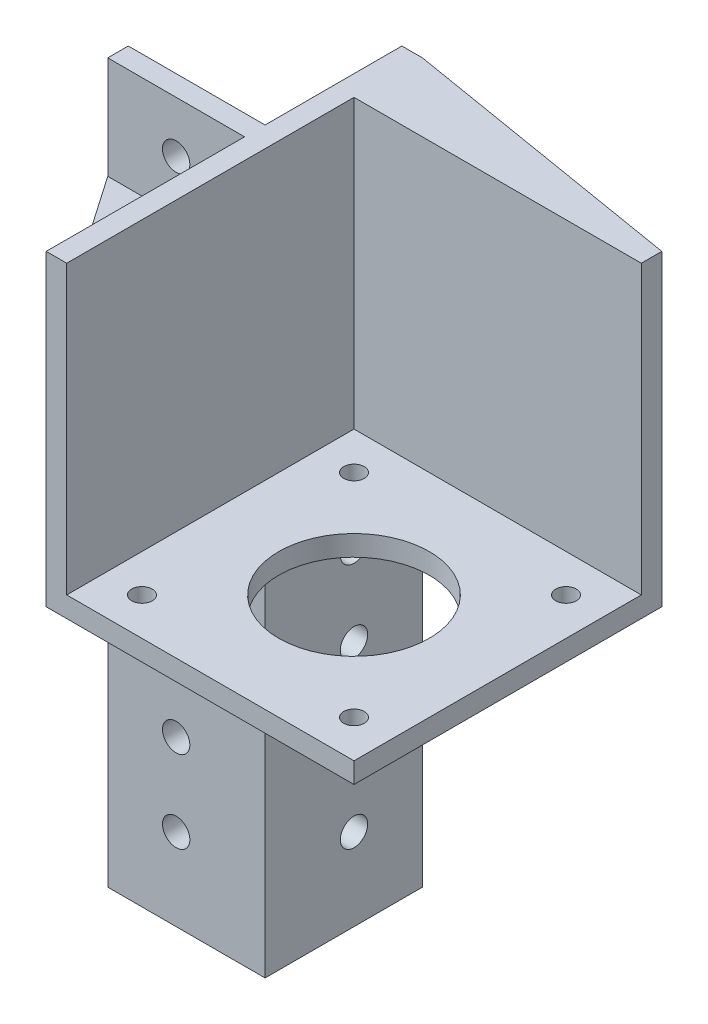
from build123d import *

# Parameters (mm, degrees)
SKETCH1_W           = 42
SKETCH1_H           = 42
SKETCH1_R           = 11
SKETCH1_R_2         = 1.5
BOSS_EXTRUDE1_DEPTH = 3
BOSS_EXTRUDE2_DEPTH = 3
SKETCH4_W           = 42
SKETCH4_H           = 45
BOSS_EXTRUDE3_DEPTH = 3
BOSS_EXTRUDE4_DEPTH = 3
BOSS_EXTRUDE5_DEPTH = 30
SKETCH7_R           = 2
CUT_EXTRUDE1_DEPTH  = 24
BOSS_EXTRUDE6_DEPTH = 45
SKETCH9_R           = 2
CUT_EXTRUDE2_DEPTH  = 24


with BuildPart() as part:
    # Sketch1 → Boss-Extrude1 (new body)
    with BuildSketch(Plane(origin=(0, 0, 0), x_dir=(1, 0, 0), z_dir=(0, 1, 0))):
        Rectangle(SKETCH1_W, SKETCH1_H)
        Circle(SKETCH1_R, mode=Mode.SUBTRACT)
        with Locations((-15.5, -15.5)):
            Circle(SKETCH1_R_2, mode=Mode.SUBTRACT)
        with Locations((15.5, -15.5)):
            Circle(SKETCH1_R_2, mode=Mode.SUBTRACT)
        with Locations((-15.5, 15.5)):
            Circle(SKETCH1_R_2, mode=Mode.SUBTRACT)
        with Locations((15.5, 15.5)):
            Circle(SKETCH1_R_2, mode=Mode.SUBTRACT)
    extrude(amount=BOSS_EXTRUDE1_DEPTH)

    # Sketch2 → Boss-Extrude2 (add)
    with BuildSketch(Plane.ZY.offset(21)):
        Polygon((-11, 0), (-11, -60), (-31, -60), (-31, 45), (21, 45), (21, 0), align=None)
    extrude(amount=BOSS_EXTRUDE2_DEPTH)

    # Sketch4 → Boss-Extrude3 (add)
    with BuildSketch(Plane(origin=(0, 0, -21), x_dir=(-1, 0, 0), z_dir=(0, 0, -1))):
        with Locations((0, 22.5)):
            Rectangle(SKETCH4_W, SKETCH4_H)
    extrude(amount=BOSS_EXTRUDE3_DEPTH)

    # Sketch5 → Boss-Extrude4 (add)
    with BuildSketch(Plane.XY.offset(-11)):
        Polygon((-44, -60), (-21, -60), (-21, 0), (-24, 0), (-24, 45), (-44, 45), align=None)
    extrude(amount=BOSS_EXTRUDE4_DEPTH)

    # Sketch6 → Boss-Extrude5 (add)
    with BuildSketch(Plane.XZ):
        Polygon((-24, 21), (-44, -8), (-24, -8), align=None)
    extrude(amount=-BOSS_EXTRUDE5_DEPTH)

    # Sketch7 → Cut-Extrude1 (cut, through all)
    with BuildSketch(Plane.XY.offset(-8)):
        with Locations((-34, 37.5)):
            Circle(SKETCH7_R)
        with Locations((-34, -12)):
            Circle(SKETCH7_R)
        with Locations((-34, -24)):
            Circle(SKETCH7_R)
        with Locations((-34, -36)):
            Circle(SKETCH7_R)
        with Locations((-34, -48)):
            Circle(SKETCH7_R)
    extrude(amount=-CUT_EXTRUDE1_DEPTH, mode=Mode.SUBTRACT)

    # Sketch8 → Boss-Extrude6 (add)
    with BuildSketch(Plane.XZ):
        Polygon((21, -24), (-21, -31), (-21, -24), align=None)
    extrude(amount=-BOSS_EXTRUDE6_DEPTH)

    # Sketch9 → Cut-Extrude2 (cut, through all)
    with BuildSketch(Plane(origin=(-21, 0, 0), x_dir=(0, 0, -1), z_dir=(1, 0, 0))):
        with Locations((21, -12)):
            Circle(SKETCH9_R)
        with Locations((21, -24)):
            Circle(SKETCH9_R)
        with Locations((21, -36)):
            Circle(SKETCH9_R)
        with Locations((21, -48)):
            Circle(SKETCH9_R)
    extrude(amount=-CUT_EXTRUDE2_DEPTH, mode=Mode.SUBTRACT)


solid = part.part
